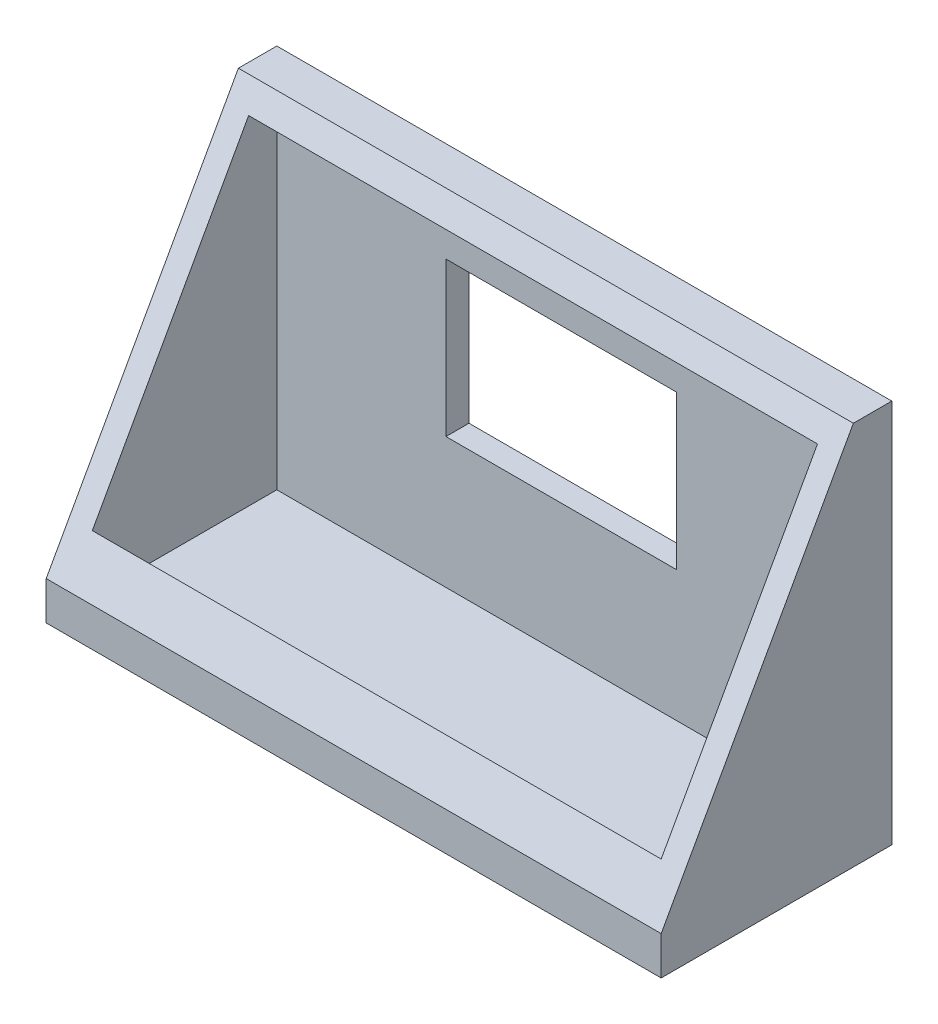
from build123d import *

# Parameters (mm, degrees)
P_IDAT_VYSUNUT_M1_DEPTH  = 40
SKO_EPINA1_T             = -3
SKICA2_W                 = 30
SKICA2_H                 = 20
ODEBRAT_VYSUNUT_M1_DEPTH = 80
SKICA2_3_R               = 5
SKICA2_3_R_2             = 4
P_IDAT_VYSUNUT_M2_DEPTH  = 5


with BuildPart() as part:
    # Skica1 → P_idat vysunut_m1 (new, symmetric)
    with BuildSketch(Plane(origin=(0, 0, 0), x_dir=(0, 0, -1), z_dir=(1, 0, 0))):
        Polygon((-30, 0), (0, 0), (0, 50), (-5, 50), (-30, 5), align=None)
    extrude(amount=P_IDAT_VYSUNUT_M1_DEPTH, both=True)

    # Sko_epina1
    sko_epina1_openings = [part.faces().sort_by_distance(p)[0] for p in [
        (0, 27.5, 17.5),
    ]]
    offset(amount=SKO_EPINA1_T, openings=sko_epina1_openings, kind=Kind.INTERSECTION)

    # Skica2 → Odebrat vysunut_m1 (cut)
    with BuildSketch(Plane(origin=(0, 0, 0), x_dir=(-1, 0, 0), z_dir=(0, 0, -1))):
        with Locations((0, 30)):
            Rectangle(SKICA2_W, SKICA2_H)
    extrude(amount=-ODEBRAT_VYSUNUT_M1_DEPTH, mode=Mode.SUBTRACT)

    # Skica2_3 → P_idat vysunut_m2 (add)
    with BuildSketch(Plane(origin=(0, 0, 0), x_dir=(-1, 0, 0), z_dir=(0, 0, -1))):
        with Locations((-30, 30)):
            Circle(SKICA2_3_R)
        with Locations((-30, 30)):
            Circle(SKICA2_3_R_2, mode=Mode.SUBTRACT)
    p_idat_vysunut_m2 = extrude(amount=P_IDAT_VYSUNUT_M2_DEPTH)

    # Zrcadlit1: P_idat vysunut_m2 across plane
    add(p_idat_vysunut_m2.mirror(Plane(origin=(0, 0, 0), x_dir=(0, 0, 1), z_dir=(1, 0, 0))))


solid = part.part
